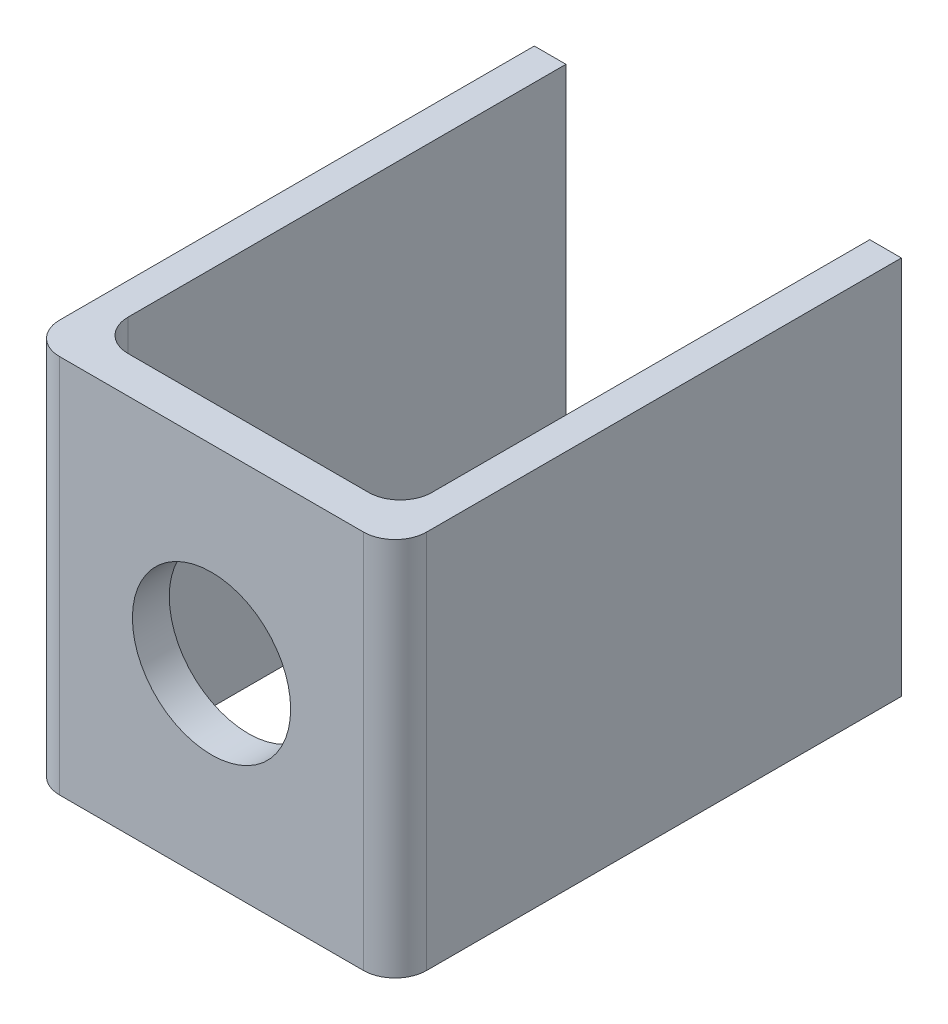
from build123d import *

# Parameters (mm, degrees)
EXTRUDE_1_DEPTH     = 60
SKETCH_2_R          = 12.5
CUT_EXTRUDE_1_DEPTH = 81


with BuildPart() as part:
    # Эскиз1 → Бобышка-Вытянуть1 (new body)
    with BuildSketch(Plane(origin=(0, 0, 0), x_dir=(1, 0, 0), z_dir=(0, 1, 0))):
        with BuildLine():
            Line((0, 80), (0, 5))
            ThreePointArc((0, 5), (1.464466094, 1.464466094), (5, 0))
            Line((5, 0), (53, 0))
            ThreePointArc((53, 0), (56.535533906, 1.464466094), (58, 5))
            Line((58, 5), (58, 80))
            Line((58, 80), (53, 80))
            Line((53, 80), (53, 10.822157735))
            ThreePointArc((53, 10.822157735), (51.535533906, 7.286623829), (48, 5.822157735))
            Line((48, 5.822157735), (10, 5.822157735))
            ThreePointArc((10, 5.822157735), (6.464466094, 7.286623829), (5, 10.822157735))
            Line((5, 10.822157735), (5, 80))
            Line((5, 80), (0, 80))
        make_face()
    extrude(amount=EXTRUDE_1_DEPTH)

    # Эскиз2 → Вырез-Вытянуть1 (cut, through all)
    with BuildSketch(Plane.XY):
        with Locations((29, 30)):
            Circle(SKETCH_2_R)
    extrude(amount=-CUT_EXTRUDE_1_DEPTH, mode=Mode.SUBTRACT)


solid = part.part
